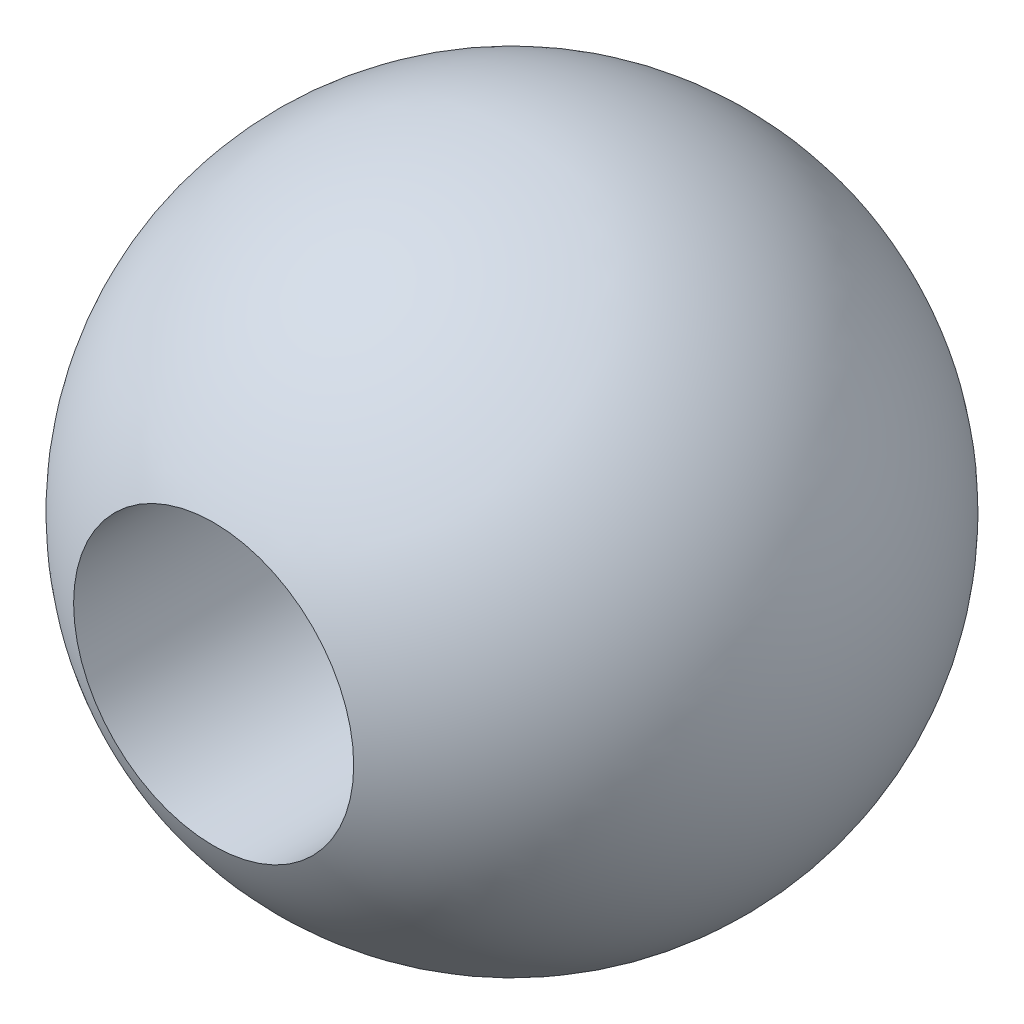
from build123d import *

# Parameters (mm, degrees)
SKETCH_4_R               = 0.85
CUT_EXTRUDE_2_DEPTH      = 3
CUT_EXTRUDE_2_DEPTH_BACK = 3


with BuildPart() as part:
    # 草图2 → 旋转1 (revolve)
    with BuildSketch(Plane(origin=(0, 0, 0), x_dir=(1, 0, 0), z_dir=(0, 1, 0))):
        with BuildLine():
            Line((-34.519344789, 0), (-30.519344789, 0))
            ThreePointArc((-30.519344789, 0), (-32.519344789, 2), (-34.519344789, 0))
        make_face()
    revolve(axis=Axis((-34.519344789, 0, 0), (1, 0, 0)))

    # 草图4 → 切除-拉伸2 (cut, two sides)
    with BuildSketch(Plane.XY) as cut_extrude_2_sk:
        with Locations((-32.519344789, 0)):
            Circle(SKETCH_4_R)
    extrude(amount=CUT_EXTRUDE_2_DEPTH, mode=Mode.SUBTRACT)
    extrude(cut_extrude_2_sk.sketch, amount=-CUT_EXTRUDE_2_DEPTH_BACK, mode=Mode.SUBTRACT)


solid = part.part
